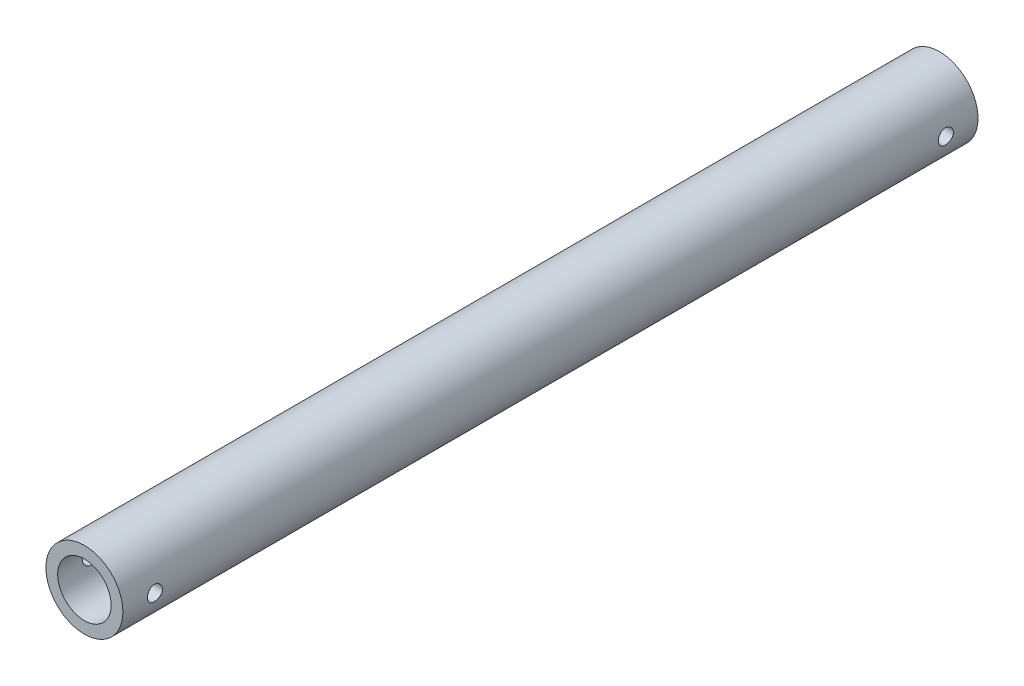
from build123d import *

# Parameters (mm, degrees)
SKETCH_1_R               = 9
SKETCH_1_R_2             = 6.25
EXTRUDE_1_DEPTH          = 200
SKETCH_2_R               = 1.75
CUT_EXTRUDE_1_DEPTH      = 10
CUT_EXTRUDE_1_DEPTH_BACK = 10


with BuildPart() as part:
    # ｽｹｯﾁ1 → ﾎﾞｽ - 押し出し1 (new body)
    with BuildSketch(Plane.XY):
        Circle(SKETCH_1_R)
        Circle(SKETCH_1_R_2, mode=Mode.SUBTRACT)
    extrude(amount=EXTRUDE_1_DEPTH)

    # ｽｹｯﾁ2 → ｶｯﾄ - 押し出し1 (cut, two sides)
    with BuildSketch(Plane(origin=(0, 0, 0), x_dir=(0, 0, -1), z_dir=(1, 0, 0))) as cut_extrude_1_sk:
        with Locations((-7.5, 0)):
            Circle(SKETCH_2_R)
        with Locations((-192.5, 0)):
            Circle(SKETCH_2_R)
    extrude(amount=CUT_EXTRUDE_1_DEPTH, mode=Mode.SUBTRACT)
    extrude(cut_extrude_1_sk.sketch, amount=-CUT_EXTRUDE_1_DEPTH_BACK, mode=Mode.SUBTRACT)


solid = part.part
